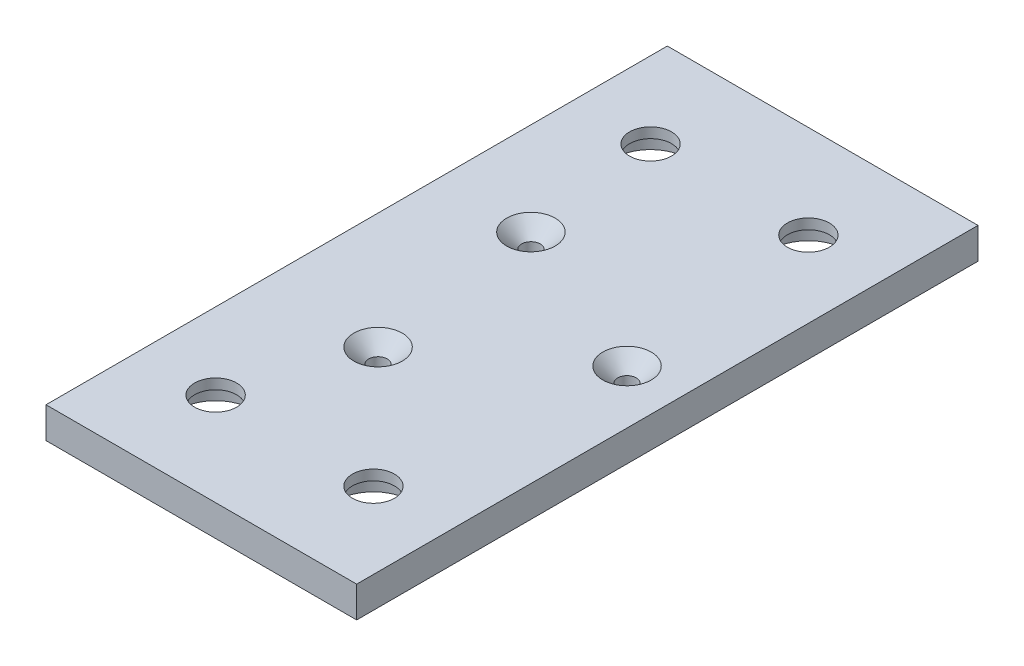
from build123d import *

# Parameters (mm, degrees)
SKETCH1_W                                        = 50
SKETCH1_H                                        = 100
BOSS_EXTRUDE1_DEPTH                              = 5
SKETCH3_R                                        = 1.5
CUT_EXTRUDE2_DEPTH                               = 5
CHAMFER1_SIZE                                    = 2.4
CBORE_FOR_1_4_BUTTON_HEAD_CAP_SCREW2_D           = 6.7564
CBORE_FOR_1_4_BUTTON_HEAD_CAP_SCREW2_CBORE_D     = 11.90752
CBORE_FOR_1_4_BUTTON_HEAD_CAP_SCREW2_CBORE_DEPTH = 3.3528


with BuildPart() as part:
    # Sketch1 → Boss-Extrude1 (new body)
    with BuildSketch(Plane(origin=(0, 0, 0), x_dir=(1, 0, 0), z_dir=(0, 1, 0))):
        Rectangle(SKETCH1_W, SKETCH1_H)
    extrude(amount=BOSS_EXTRUDE1_DEPTH)

    # Sketch3 → Cut-Extrude2 (cut)
    with BuildSketch(Plane(origin=(0, 5, 0), x_dir=(1, 0, 0), z_dir=(0, 1, 0))):
        with Locations((-6.314276634, -15.244012286)):
            Circle(SKETCH3_R)
        with Locations((16.358840213, 2.153682172)):
            Circle(SKETCH3_R)
        with Locations((-10.044563579, 13.090330115)):
            Circle(SKETCH3_R)
    extrude(amount=-CUT_EXTRUDE2_DEPTH, mode=Mode.SUBTRACT)

    # Chamfer1
    chamfer1_edges = [part.edges().sort_by_distance(p)[0] for p in [
        (-7.814276634, 5, 15.244012286),
        (14.858840213, 5, -2.153682172),
        (-11.544563579, 5, -13.090330115),
    ]]
    chamfer(chamfer1_edges, length=CHAMFER1_SIZE)

    # CBORE for 1/4 Button Head Cap Screw2 (through all)
    with Locations(Plane(origin=(0, 0, 0), x_dir=(-1, 0, 0), z_dir=(0, -1, 0))):
        with Locations((12.7, -35), (-12.7, -35), (-12.7, 35), (12.7, 35)):
            CounterBoreHole(CBORE_FOR_1_4_BUTTON_HEAD_CAP_SCREW2_D / 2, CBORE_FOR_1_4_BUTTON_HEAD_CAP_SCREW2_CBORE_D / 2, CBORE_FOR_1_4_BUTTON_HEAD_CAP_SCREW2_CBORE_DEPTH)


solid = part.part
